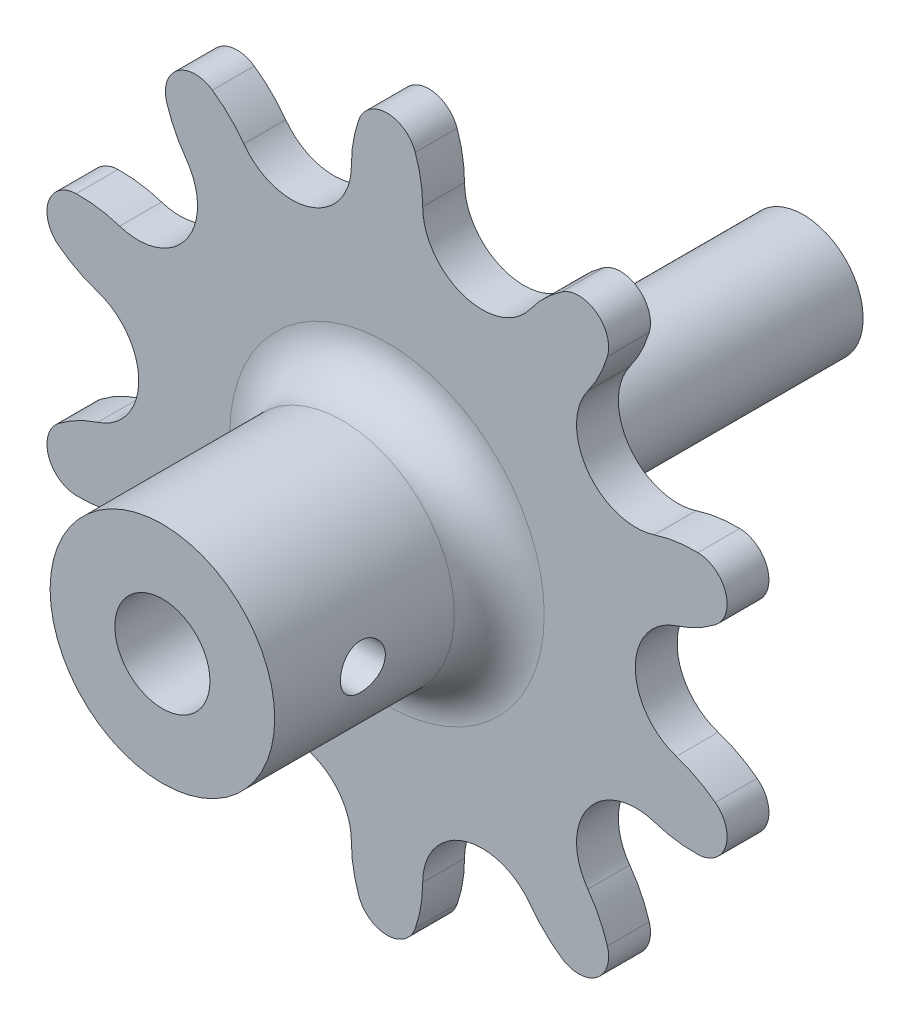
from build123d import *

# Parameters (mm, degrees)
BOSS_EXTRUDE1_DEPTH = 2.794
SKETCH3_R           = 7.5
SKETCH3_R_2         = 3.175
BOSS_EXTRUDE2_DEPTH = 15
FILLET1_R           = 3
SKETCH4_R           = 1.5
CUT_EXTRUDE1_DEPTH  = 7.5
SKETCH5_R           = 4
BOSS_EXTRUDE3_DEPTH = 25


with BuildPart() as part:
    # Sketch2 → Boss-Extrude1 (new body)
    with BuildSketch(Plane.XY):
        with BuildLine():
            ThreePointArc((-8.73125, 0), (-8.606730181, 1.469327109), (-8.236722377, 2.896744905))
            ThreePointArc((-8.236722377, 2.896744905), (-6.35, 4.233209924), (-4.463277623, 2.896744905))
            ThreePointArc((-4.463277623, 2.896744905), (-4.093269819, 1.469327109), (-3.96875, 0))
            ThreePointArc((-3.96875, 0), (-3.210786196, -2.33277272), (-1.226411196, -3.774505549))
            ThreePointArc((-1.226411196, -3.774505549), (1.226411196, -3.774505549), (3.210786196, -2.33277272))
            ThreePointArc((3.210786196, -2.33277272), (4.175173652, -1.217253032), (5.313531383, -0.279932907))
            ThreePointArc((5.313531383, -0.279932907), (7.625476277, -0.307697583), (8.366312316, -2.497908084))
            ThreePointArc((8.366312316, -2.497908084), (7.826639788, -3.870198469), (7.063729632, -5.132099984))
            ThreePointArc((7.063729632, -5.132099984), (6.305765829, -7.464872704), (7.063729632, -9.797645424))
            ThreePointArc((7.063729632, -9.797645424), (9.048104632, -11.239378253), (11.500927025, -11.239378253))
            ThreePointArc((11.500927025, -11.239378253), (12.936818887, -10.903756591), (14.408712583, -10.814558567))
            ThreePointArc((14.408712583, -10.814558567), (16.262795625, -12.195947775), (15.574771139, -14.403317789))
            ThreePointArc((15.574771139, -14.403317789), (14.331554842, -15.19631248), (12.972620461, -15.768784912))
            ThreePointArc((12.972620461, -15.768784912), (10.988245461, -17.210517741), (10.230281657, -19.543290461))
            ThreePointArc((10.230281657, -19.543290461), (10.988245461, -21.876063181), (12.972620461, -23.31779601))
            ThreePointArc((12.972620461, -23.31779601), (14.331554842, -23.890268442), (15.574771139, -24.683263133))
            ThreePointArc((15.574771139, -24.683263133), (16.262795625, -26.890633147), (14.408712583, -28.272022355))
            ThreePointArc((14.408712583, -28.272022355), (12.936818887, -28.182824331), (11.500927025, -27.847202669))
            ThreePointArc((11.500927025, -27.847202669), (9.048104632, -27.847202669), (7.063729632, -29.288935498))
            ThreePointArc((7.063729632, -29.288935498), (6.305765829, -31.621708218), (7.063729632, -33.954480938))
            ThreePointArc((7.063729632, -33.954480938), (7.826639788, -35.216382453), (8.366312316, -36.588672839))
            ThreePointArc((8.366312316, -36.588672839), (7.625476277, -38.778883339), (5.313531383, -38.806648015))
            ThreePointArc((5.313531383, -38.806648015), (4.175173652, -37.869327891), (3.210786196, -36.753808202))
            ThreePointArc((3.210786196, -36.753808202), (1.226411196, -35.312075373), (-1.226411196, -35.312075373))
            ThreePointArc((-1.226411196, -35.312075373), (-3.210786196, -36.753808202), (-3.96875, -39.086580922))
            ThreePointArc((-3.96875, -39.086580922), (-4.093269819, -40.555908031), (-4.463277623, -41.983325828))
            ThreePointArc((-4.463277623, -41.983325828), (-6.35, -43.319790846), (-8.236722377, -41.983325828))
            ThreePointArc((-8.236722377, -41.983325828), (-8.606730181, -40.555908031), (-8.73125, -39.086580922))
            ThreePointArc((-8.73125, -39.086580922), (-9.489213804, -36.753808202), (-11.473588804, -35.312075373))
            ThreePointArc((-11.473588804, -35.312075373), (-13.926411196, -35.312075373), (-15.910786196, -36.753808202))
            ThreePointArc((-15.910786196, -36.753808202), (-16.875173652, -37.869327891), (-18.013531383, -38.806648015))
            ThreePointArc((-18.013531383, -38.806648015), (-20.325476277, -38.778883339), (-21.066312316, -36.588672839))
            ThreePointArc((-21.066312316, -36.588672839), (-20.526639788, -35.216382453), (-19.763729632, -33.954480938))
            ThreePointArc((-19.763729632, -33.954480938), (-19.005765829, -31.621708218), (-19.763729632, -29.288935498))
            ThreePointArc((-19.763729632, -29.288935498), (-21.748104632, -27.847202669), (-24.200927025, -27.847202669))
            ThreePointArc((-24.200927025, -27.847202669), (-25.636818887, -28.182824331), (-27.108712583, -28.272022355))
            ThreePointArc((-27.108712583, -28.272022355), (-28.962795625, -26.890633147), (-28.274771139, -24.683263133))
            ThreePointArc((-28.274771139, -24.683263133), (-27.031554842, -23.890268442), (-25.672620461, -23.31779601))
            ThreePointArc((-25.672620461, -23.31779601), (-23.688245461, -21.876063181), (-22.930281657, -19.543290461))
            ThreePointArc((-22.930281657, -19.543290461), (-23.688245461, -17.210517741), (-25.672620461, -15.768784912))
            ThreePointArc((-25.672620461, -15.768784912), (-27.031554842, -15.19631248), (-28.274771139, -14.403317789))
            ThreePointArc((-28.274771139, -14.403317789), (-28.962795625, -12.195947775), (-27.108712583, -10.814558567))
            ThreePointArc((-27.108712583, -10.814558567), (-25.636818887, -10.903756591), (-24.200927025, -11.239378253))
            ThreePointArc((-24.200927025, -11.239378253), (-21.748104632, -11.239378253), (-19.763729632, -9.797645424))
            ThreePointArc((-19.763729632, -9.797645424), (-19.005765829, -7.464872704), (-19.763729632, -5.132099984))
            ThreePointArc((-19.763729632, -5.132099984), (-20.526639788, -3.870198469), (-21.066312316, -2.497908084))
            ThreePointArc((-21.066312316, -2.497908084), (-20.325476277, -0.307697583), (-18.013531383, -0.279932907))
            ThreePointArc((-18.013531383, -0.279932907), (-16.875173652, -1.217253032), (-15.910786196, -2.33277272))
            ThreePointArc((-15.910786196, -2.33277272), (-13.926411196, -3.774505549), (-11.473588804, -3.774505549))
            ThreePointArc((-11.473588804, -3.774505549), (-9.489213804, -2.33277272), (-8.73125, 0))
        make_face()
    extrude(amount=BOSS_EXTRUDE1_DEPTH)

    # Sketch3 → Boss-Extrude2 (add)
    with BuildSketch(Plane.XY.offset(2.794)):
        with Locations((-6.35, -19.543290461)):
            Circle(SKETCH3_R)
        with Locations((-6.35, -19.543290461)):
            Circle(SKETCH3_R_2, mode=Mode.SUBTRACT)
    extrude(amount=BOSS_EXTRUDE2_DEPTH)

    # Fillet1
    fillet1_edges = [part.edges().sort_by_distance(p)[0] for p in [
        (-13.85, -19.543290461, 2.794),
    ]]
    fillet(fillet1_edges, radius=FILLET1_R)

    # Sketch4 → Cut-Extrude1 (cut, symmetric)
    with BuildSketch(Plane(origin=(0, 0, 0), x_dir=(0, 0, -1), z_dir=(1, 0, 0))):
        with Locations((-11.906147171, -19.543290461)):
            Circle(SKETCH4_R)
    extrude(amount=CUT_EXTRUDE1_DEPTH, both=True, mode=Mode.SUBTRACT)

    # Sketch5 → Boss-Extrude3 (add)
    with BuildSketch(Plane(origin=(0, 0, 0), x_dir=(-1, 0, 0), z_dir=(0, 0, -1))):
        with Locations((6.35, -19.543290461)):
            Circle(SKETCH5_R)
    extrude(amount=BOSS_EXTRUDE3_DEPTH)


solid = part.part
